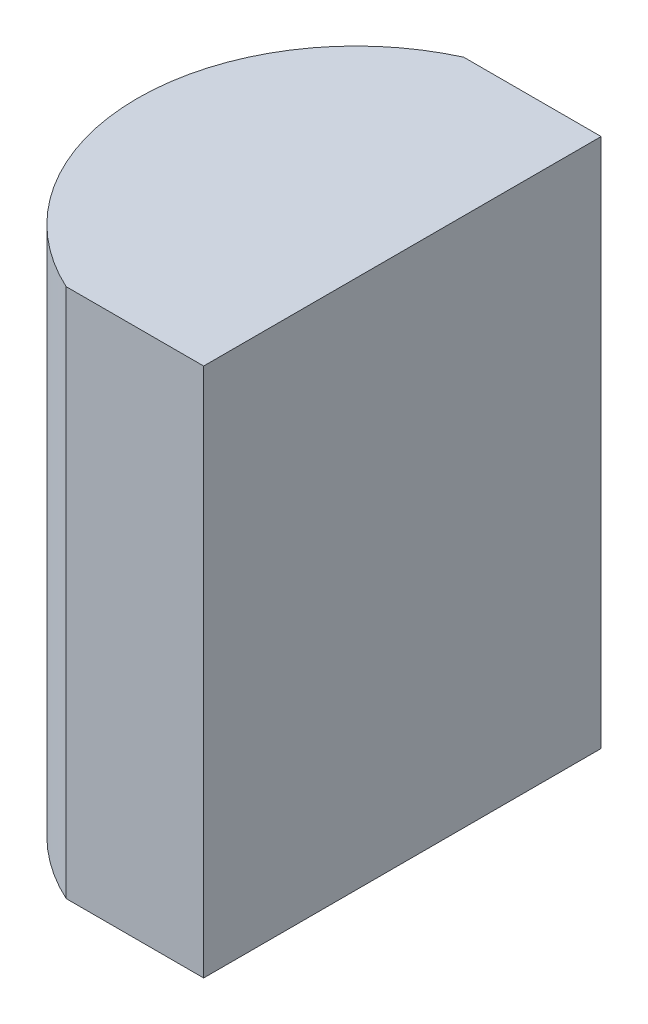
from build123d import *

# Parameters (mm, degrees)
EXTRUDE_1_DEPTH = 8


with BuildPart() as part:
    # 草图1 → 凸台-拉伸1 (new body)
    with BuildSketch(Plane(origin=(0, 0, 0), x_dir=(1, 0, 0), z_dir=(0, 1, 0))):
        with BuildLine():
            Line((2.980431626, 3), (5.055204335, 3))
            Line((5.055204335, 3), (5.055204335, -3))
            Line((5.055204335, -3), (2.980431626, -3))
            ThreePointArc((2.980431626, -3), (1.055204335, 0), (2.980431626, 3))
        make_face()
    extrude(amount=EXTRUDE_1_DEPTH)


solid = part.part
